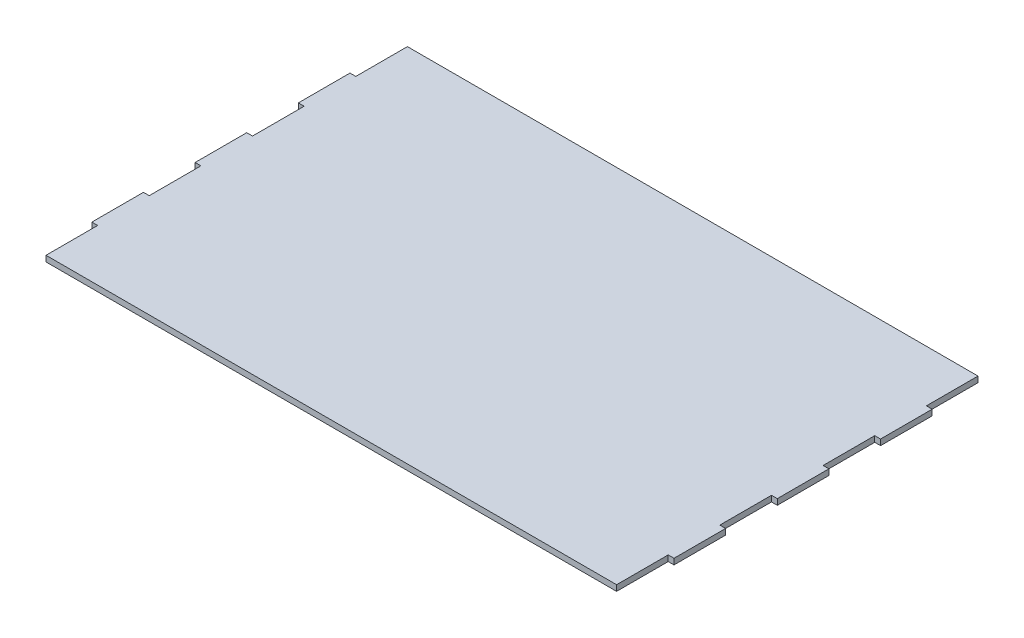
from build123d import *

# Parameters (mm, degrees)
SALIENTE_EXTRUIR1_DEPTH = 3


with BuildPart() as part:
    # Croquis2 → Saliente-Extruir1 (new body)
    with BuildSketch(Plane(origin=(0, 0, 0), x_dir=(1, 0, 0), z_dir=(0, 1, 0))):
        Polygon((-136.186205064, -58.809840181), (158.88812269, -58.809840181), (158.88812269, -32.109840181), (161.88812269, -32.109840181), (161.88812269, -5.409840181), (158.88812269, -5.409840181), (158.88812269, 21.290159819), (161.88812269, 21.290159819), (161.88812269, 47.990159819), (158.88812269, 47.990159819), (158.88812269, 74.690159819), (161.88812269, 74.690159819), (161.88812269, 101.390159819), (158.88812269, 101.390159819), (158.88812269, 128.090159819), (-136.186205064, 128.090159819), (-136.186205064, 101.390159819), (-139.186205064, 101.390159819), (-139.186205064, 74.690159819), (-136.186205064, 74.690159819), (-136.186205064, 47.990159819), (-139.186205064, 47.990159819), (-139.186205064, 21.290159819), (-136.186205064, 21.290159819), (-136.186205064, -5.409840181), (-139.186205064, -5.409840181), (-139.186205064, -32.109840181), (-136.186205064, -32.109840181), align=None)
    extrude(amount=SALIENTE_EXTRUIR1_DEPTH)


solid = part.part
